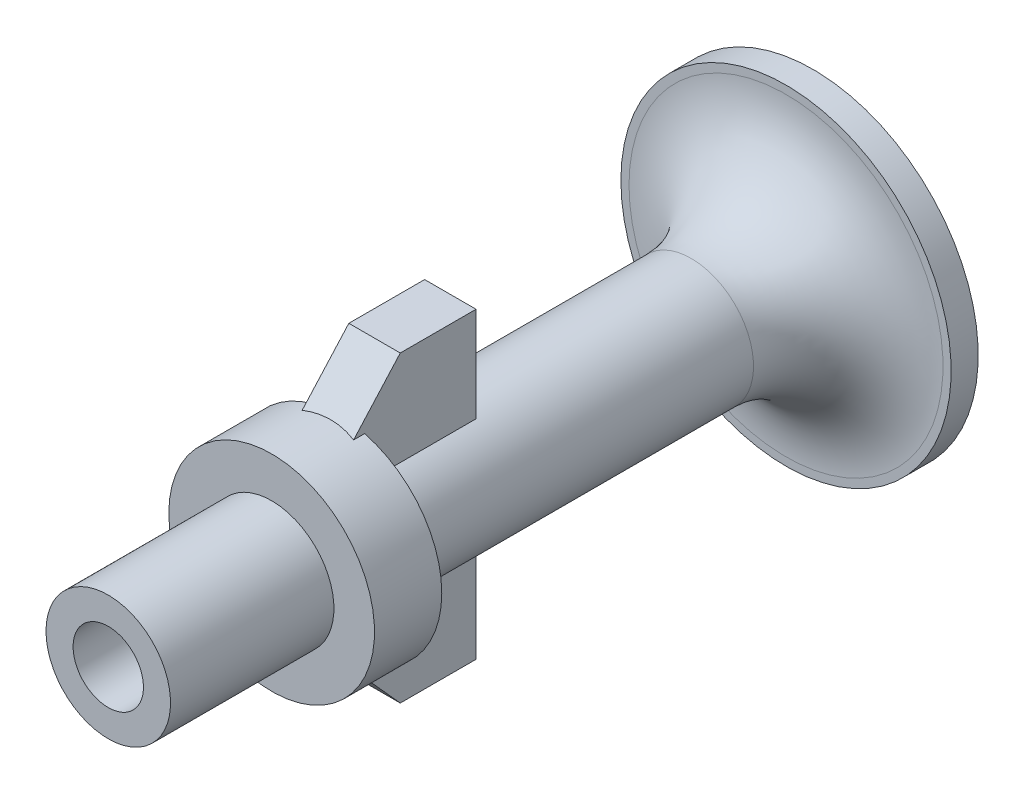
from build123d import *

# Parameters (mm, degrees)
BOSS_EXTRUDE1_DEPTH      = 0.95
BOSS_EXTRUDE1_DEPTH_BACK = 0.95


with BuildPart() as part:
    # Sketch1 → Revolve1 (revolve)
    with BuildSketch(Plane(origin=(0, 0, 0), x_dir=(0, 0, -1), z_dir=(1, 0, 0))):
        with BuildLine():
            Line((10.463274616, 2.3), (16.499380089, 2.3))
            Line((16.499380089, 2.3), (16.499380089, 3.8))
            Line((16.499380089, 3.8), (18.983450943, 3.8))
            Line((18.983450943, 3.8), (18.983450943, 2.3))
            Line((18.983450943, 2.3), (32, 2.3))
            ThreePointArc((32, 2.3), (34.474873734, 3.325126266), (35.5, 5.8))
            Line((35.5, 5.8), (35.5, 6.1))
            Line((35.5, 6.1), (36.5, 6.1))
            Line((36.5, 6.1), (36.5, 5.078211692))
            Line((36.5, 5.078211692), (34.771119215, 2.72674277))
            ThreePointArc((34.771119215, 2.72674277), (33.531386801, 1.676988608), (31.951260272, 1.3))
            Line((31.951260272, 1.3), (10.463274616, 1.3))
            Line((10.463274616, 1.3), (10.463274616, 2.3))
        make_face()
    revolve(axis=Axis((0, 0, -15.3), (0, 0, 1)))

    # Sketch2 → Boss-Extrude1 (add, two sides: drawn at the far end of the back side and taken through both)
    with BuildSketch(Plane(origin=(0, 0, 0), x_dir=(0, 0, -1), z_dir=(1, 0, 0)).offset(-BOSS_EXTRUDE1_DEPTH_BACK)):
        Polygon((23.1, 1.460737541), (23.1, 5.6), (20.3, 5.6), (16.583846242, 1.460737541), align=None)
        Polygon((16.583846242, -1.460737541), (23.1, -1.460737541), (23.1, -5.6), (20.3, -5.6), align=None)
    extrude(amount=BOSS_EXTRUDE1_DEPTH + BOSS_EXTRUDE1_DEPTH_BACK)


solid = part.part
